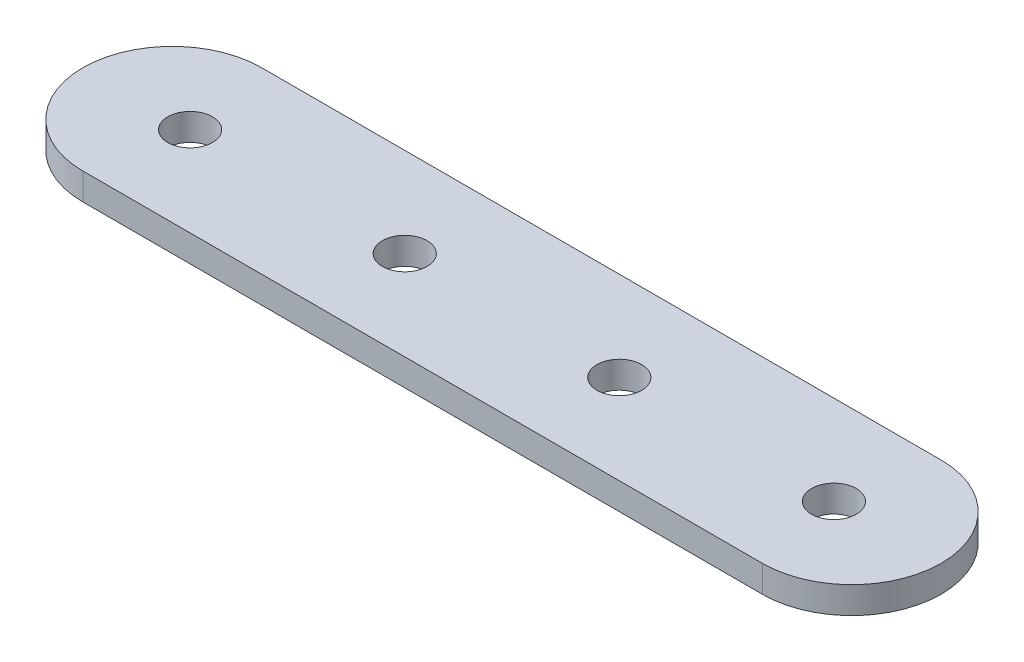
from build123d import *

# Parameters (mm, degrees)
SKETCH_1_R      = 2.5
EXTRUDE_1_DEPTH = 3


with BuildPart() as part:
    # 草图1 → 凸台-拉伸1 (new body)
    with BuildSketch(Plane(origin=(0, 0, 0), x_dir=(1, 0, 0), z_dir=(0, 1, 0))):
        with BuildLine():
            Line((10, 0), (86, 0))
            ThreePointArc((86, 0), (96, 10), (86, 20))
            Line((86, 20), (10, 20))
            ThreePointArc((10, 20), (0, 10), (10, 0))
        make_face()
        with Locations((12, 10)):
            Circle(SKETCH_1_R, mode=Mode.SUBTRACT)
        with Locations((36, 10)):
            Circle(SKETCH_1_R, mode=Mode.SUBTRACT)
        with Locations((60, 10)):
            Circle(SKETCH_1_R, mode=Mode.SUBTRACT)
        with Locations((84, 10)):
            Circle(SKETCH_1_R, mode=Mode.SUBTRACT)
    extrude(amount=EXTRUDE_1_DEPTH)


solid = part.part
